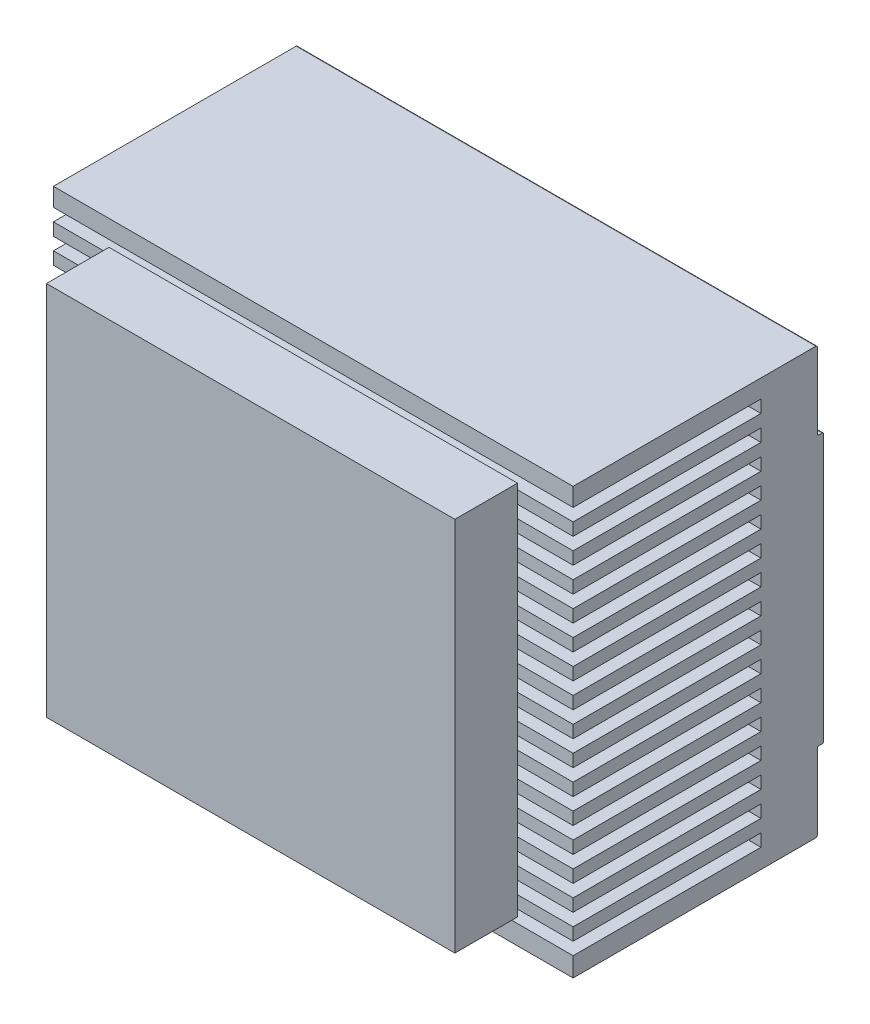
from build123d import *

# Parameters (mm, degrees)
SKETCH1_W           = 83
SKETCH1_H           = 68
BOSS_EXTRUDE1_DEPTH = 40
SKETCH2_W           = 65.230257998
SKETCH2_H           = 60
BOSS_EXTRUDE2_DEPTH = 10
SKETCH3_W           = 83
SKETCH3_H           = 2
CUT_EXTRUDE1_DEPTH  = 30
SKETCH4_W           = 83
SKETCH4_H           = 12.5
CUT_EXTRUDE2_DEPTH  = 1
FILLET1_R           = 0.25


with BuildPart() as part:
    # Sketch1 → Boss-Extrude1 (new body)
    with BuildSketch(Plane.XY):
        with Locations((41.5, 34)):
            Rectangle(SKETCH1_W, SKETCH1_H)
    extrude(amount=BOSS_EXTRUDE1_DEPTH)

    # Sketch3 → Cut-Extrude1 (cut)
    with BuildSketch(Plane.XY.offset(40)):
        with Locations((41.5, 64.081825925)):
            Rectangle(SKETCH3_W, SKETCH3_H)
        with Locations((41.5, 60.081825925)):
            Rectangle(SKETCH3_W, SKETCH3_H)
        with Locations((41.5, 56.081825925)):
            Rectangle(SKETCH3_W, SKETCH3_H)
        with Locations((41.5, 52.081825925)):
            Rectangle(SKETCH3_W, SKETCH3_H)
        with Locations((41.5, 48.081825925)):
            Rectangle(SKETCH3_W, SKETCH3_H)
        with Locations((41.5, 44.081825925)):
            Rectangle(SKETCH3_W, SKETCH3_H)
        with Locations((41.5, 40.081825925)):
            Rectangle(SKETCH3_W, SKETCH3_H)
        with Locations((41.5, 36.081825925)):
            Rectangle(SKETCH3_W, SKETCH3_H)
        with Locations((41.5, 32.081825925)):
            Rectangle(SKETCH3_W, SKETCH3_H)
        with Locations((41.5, 28.081825925)):
            Rectangle(SKETCH3_W, SKETCH3_H)
        with Locations((41.5, 24.081825925)):
            Rectangle(SKETCH3_W, SKETCH3_H)
        with Locations((41.5, 20.081825925)):
            Rectangle(SKETCH3_W, SKETCH3_H)
        with Locations((41.5, 16.081825925)):
            Rectangle(SKETCH3_W, SKETCH3_H)
        with Locations((41.5, 12.081825925)):
            Rectangle(SKETCH3_W, SKETCH3_H)
        with Locations((41.5, 8.081825925)):
            Rectangle(SKETCH3_W, SKETCH3_H)
        with Locations((41.5, 4.081825925)):
            Rectangle(SKETCH3_W, SKETCH3_H)
    extrude(amount=-CUT_EXTRUDE1_DEPTH, mode=Mode.SUBTRACT)

    # Sketch4 → Cut-Extrude2 (cut)
    with BuildSketch(Plane(origin=(0, 0, 0), x_dir=(-1, 0, 0), z_dir=(0, 0, -1))):
        with Locations((-41.5, 61.75)):
            Rectangle(SKETCH4_W, SKETCH4_H)
        with Locations((-41.5, 6.25)):
            Rectangle(SKETCH4_W, SKETCH4_H)
    extrude(amount=-CUT_EXTRUDE2_DEPTH, mode=Mode.SUBTRACT)

    # Fillet1
    fillet1_edges = [part.edges().sort_by_distance(p)[0] for p in [
        (41.5, 55.5, 0),
        (41.5, 68, 1),
        (41.5, 55.5, 1),
        (41.5, 12.5, 0),
        (41.5, 0, 1),
        (41.5, 12.5, 1),
    ]]
    fillet(fillet1_edges, radius=FILLET1_R)


with BuildPart() as body_2:
    # Sketch2 → Boss-Extrude2 (new body)
    with BuildSketch(Plane.XY.offset(40)):
        with Locations((41.5, 34)):
            Rectangle(SKETCH2_W, SKETCH2_H)
    extrude(amount=BOSS_EXTRUDE2_DEPTH)


solid = Compound([part.part, body_2.part])
